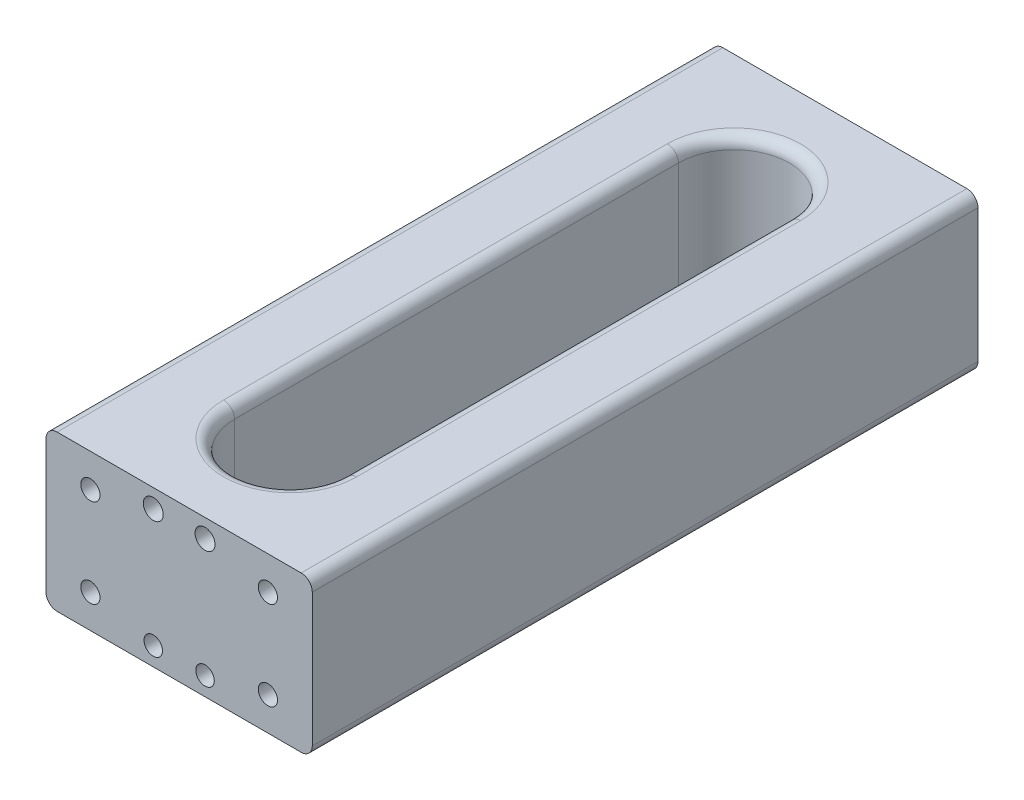
from build123d import *

# Parameters (mm, degrees)
SKETCH_1_W          = 36
SKETCH_1_H          = 21
SKETCH_1_R          = 1.25
SKETCH_1_R_2        = 1.3
SKETCH_1_R_3        = 1.35
EXTRUDE_1_DEPTH     = 90
SKETCH_1_5_R        = 1.3
SKETCH_1_5_R_2      = 1.35
SKETCH_1_5_R_3      = 1.25
CUT_EXTRUDE_1_DEPTH = 4
CUT_EXTRUDE_START   = 90
SKETCH_1_6_R        = 1.35
SKETCH_1_6_R_2      = 1.3
SKETCH_1_6_R_3      = 1.25
CUT_EXTRUDE_2_DEPTH = 4
CUT_EXTRUDE_3_REACH = 96.154
FILLET_1_R          = 1.5


with BuildPart() as part:
    # 스케치1 → 보스-돌출1 (new body)
    with BuildSketch(Plane.XY):
        Rectangle(SKETCH_1_W, SKETCH_1_H)
        with Locations((-3.5, -8)):
            Circle(SKETCH_1_R, mode=Mode.SUBTRACT)
        with Locations((3.5, -8)):
            Circle(SKETCH_1_R, mode=Mode.SUBTRACT)
        with Locations((-12, 6)):
            Circle(SKETCH_1_R_2, mode=Mode.SUBTRACT)
        with Locations((12, 6)):
            Circle(SKETCH_1_R_2, mode=Mode.SUBTRACT)
        with Locations((12, -6)):
            Circle(SKETCH_1_R_2, mode=Mode.SUBTRACT)
        with Locations((-12, -6)):
            Circle(SKETCH_1_R_2, mode=Mode.SUBTRACT)
        with Locations((3.5, 8)):
            Circle(SKETCH_1_R_3, mode=Mode.SUBTRACT)
        with Locations((-3.5, 8)):
            Circle(SKETCH_1_R_3, mode=Mode.SUBTRACT)
        with Locations((12, -6)):
            Circle(SKETCH_1_R_2)
        with Locations((3.5, -8)):
            Circle(SKETCH_1_R)
        with Locations((-3.5, -8)):
            Circle(SKETCH_1_R)
        with Locations((-12, -6)):
            Circle(SKETCH_1_R_2)
        with Locations((-12, 6)):
            Circle(SKETCH_1_R_2)
        with Locations((-3.5, 8)):
            Circle(SKETCH_1_R_3)
        with Locations((3.5, 8)):
            Circle(SKETCH_1_R_3)
        with Locations((12, 6)):
            Circle(SKETCH_1_R_2)
    extrude(amount=EXTRUDE_1_DEPTH)

    # 스케치1<5> → 컷-돌출1 (cut)
    with BuildSketch(Plane.XY):
        with Locations((12, 6)):
            Circle(SKETCH_1_5_R)
        with Locations((3.5, 8)):
            Circle(SKETCH_1_5_R_2)
        with Locations((-3.5, 8)):
            Circle(SKETCH_1_5_R_2)
        with Locations((-12, 6)):
            Circle(SKETCH_1_5_R)
        with Locations((-12, -6)):
            Circle(SKETCH_1_5_R)
        with Locations(Location((-3.5, -8, 0), (0, 0, 180))):
            Circle(SKETCH_1_5_R_3)
        with Locations((3.5, -8)):
            Circle(SKETCH_1_5_R_3)
        with Locations((12, -6)):
            Circle(SKETCH_1_5_R)
    extrude(amount=CUT_EXTRUDE_1_DEPTH, mode=Mode.SUBTRACT)

    # 스케치1<6> → 컷-돌출2 (cut)
    with BuildSketch(Plane.XY.offset(CUT_EXTRUDE_START)):
        with Locations((3.5, 8)):
            Circle(SKETCH_1_6_R)
        with Locations((12, 6)):
            Circle(SKETCH_1_6_R_2)
        with Locations((-3.5, 8)):
            Circle(SKETCH_1_6_R)
        with Locations((-12, 6)):
            Circle(SKETCH_1_6_R_2)
        with Locations((-12, -6)):
            Circle(SKETCH_1_6_R_2)
        with Locations(Location((-3.5, -8, 0), (0, 0, 180))):
            Circle(SKETCH_1_6_R_3)
        with Locations((3.5, -8)):
            Circle(SKETCH_1_6_R_3)
        with Locations((12, -6)):
            Circle(SKETCH_1_6_R_2)
    extrude(amount=-CUT_EXTRUDE_2_DEPTH, mode=Mode.SUBTRACT)

    # 스케치2 → 컷-돌출3 (cut, up to next)
    with BuildSketch(Plane(origin=(0, 10.5, 0), x_dir=(1, 0, 0), z_dir=(0, 1, 0)), mode=Mode.PRIVATE) as cut_extrude_3_sk1:
        with BuildLine():
            Line((7.5, -15), (7.5, -75))
            ThreePointArc((7.5, -75), (0, -82.5), (-7.5, -75))
            Line((-7.5, -75), (-7.5, -15))
            ThreePointArc((-7.5, -15), (0, -7.5), (7.5, -15))
        make_face()
    cut_extrude_3_tool1 = extrude(cut_extrude_3_sk1.sketch, amount=-CUT_EXTRUDE_3_REACH, mode=Mode.PRIVATE) & part.part
    add(cut_extrude_3_tool1.solids().sort_by_distance((0, 10.5, 45))[0], mode=Mode.SUBTRACT)

    # 필렛1
    fillet_1_edges = [part.edges().sort_by_distance(p)[0] for p in [
        (0, -10.5, 7.5),
        (7.5, -10.5, 45),
        (0, -10.5, 82.5),
        (-7.5, -10.5, 45),
        (0, 10.5, 7.5),
        (-7.5, 10.5, 45),
        (0, 10.5, 82.5),
        (7.5, 10.5, 45),
        (-18, 10.5, 45),
        (18, 10.5, 45),
        (18, -10.5, 45),
        (-18, -10.5, 45),
    ]]
    fillet(fillet_1_edges, radius=FILLET_1_R)


solid = part.part
